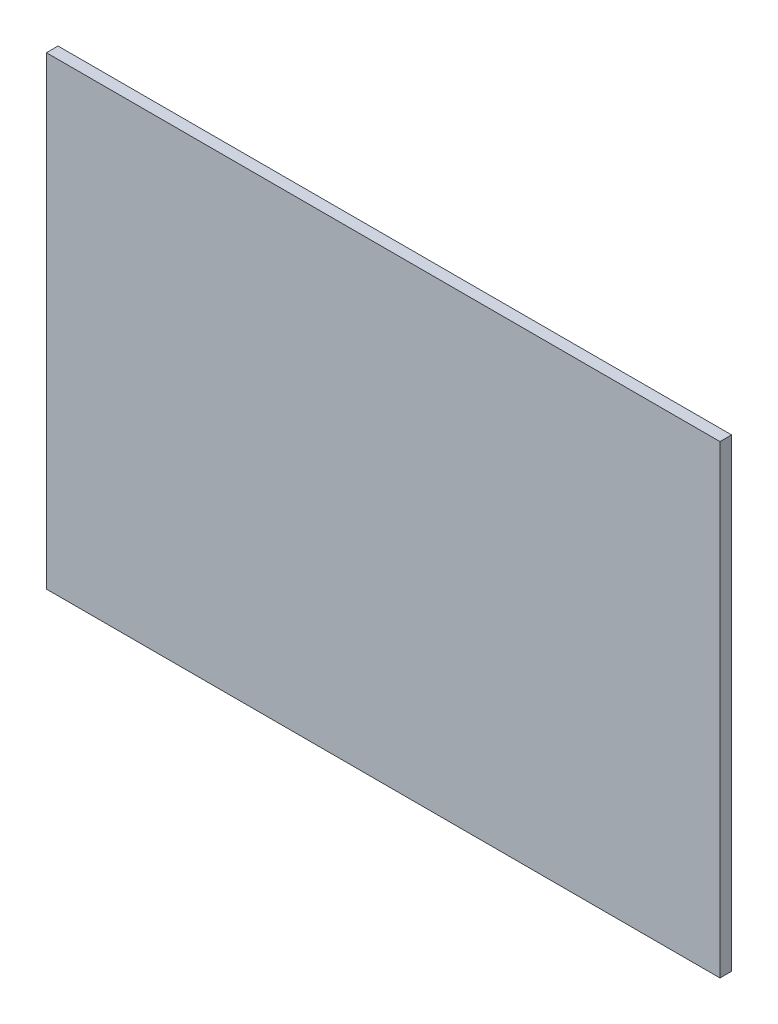
from build123d import *

# Parameters (mm, degrees)
SKETCH1_W           = 147.32
SKETCH1_H           = 101.59999746
BOSS_EXTRUDE1_DEPTH = 2.54


with BuildPart() as part:
    # Sketch1 → Boss-Extrude1 (new body)
    with BuildSketch(Plane.XY):
        with Locations((13.84745614, -15.897279432)):
            Rectangle(SKETCH1_W, SKETCH1_H)
    extrude(amount=BOSS_EXTRUDE1_DEPTH)


solid = part.part
